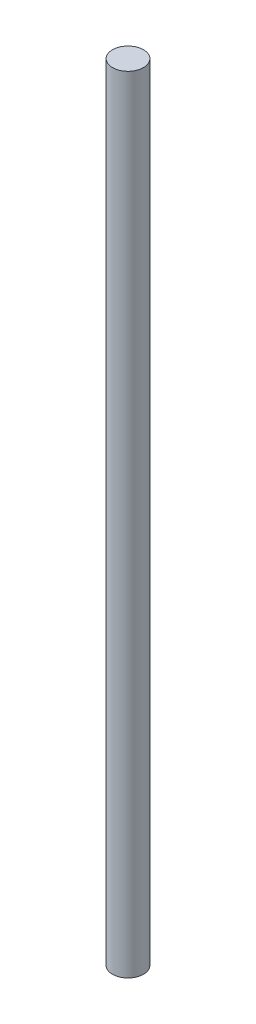
from build123d import *

# Parameters (mm, degrees)
SKETCH1_R           = 4.7625
BOSS_EXTRUDE1_DEPTH = 241.3


with BuildPart() as part:
    # Sketch1 → Boss-Extrude1 (new body)
    with BuildSketch(Plane(origin=(0, 0, 0), x_dir=(1, 0, 0), z_dir=(0, 1, 0))):
        Circle(SKETCH1_R)
    extrude(amount=BOSS_EXTRUDE1_DEPTH)


solid = part.part
